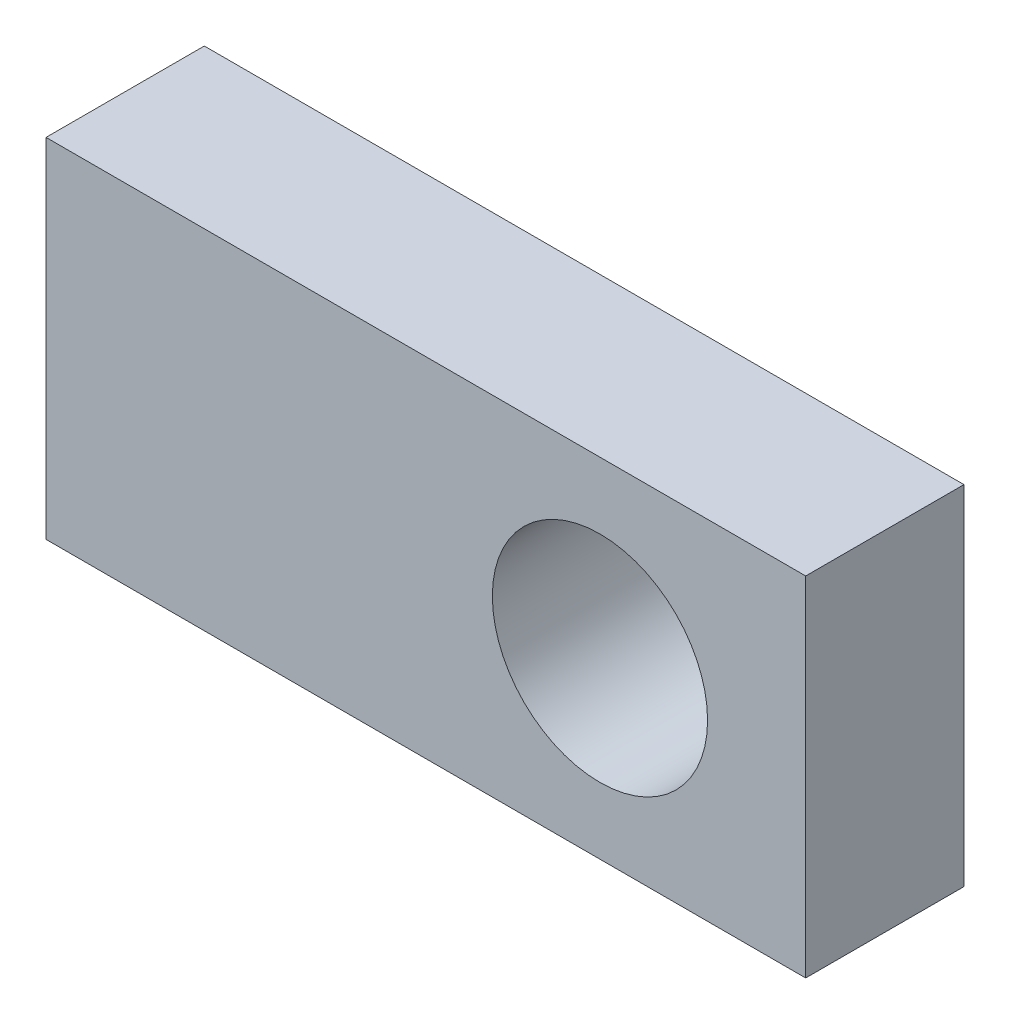
from build123d import *

# Parameters (mm, degrees)
SKIZZE1_W                       = 24
SKIZZE1_H                       = 11
SKIZZE1_R                       = 3.4
AUFSATZ_LINEAR_AUSTRAGEN1_DEPTH = 5


with BuildPart() as part:
    # Skizze1 → Aufsatz-Linear austragen1 (new body)
    with BuildSketch(Plane.XY):
        with Locations((-12, 0)):
            Rectangle(SKIZZE1_W, SKIZZE1_H)
        with Locations((-6.5, 0)):
            Circle(SKIZZE1_R, mode=Mode.SUBTRACT)
    extrude(amount=AUFSATZ_LINEAR_AUSTRAGEN1_DEPTH)


solid = part.part
